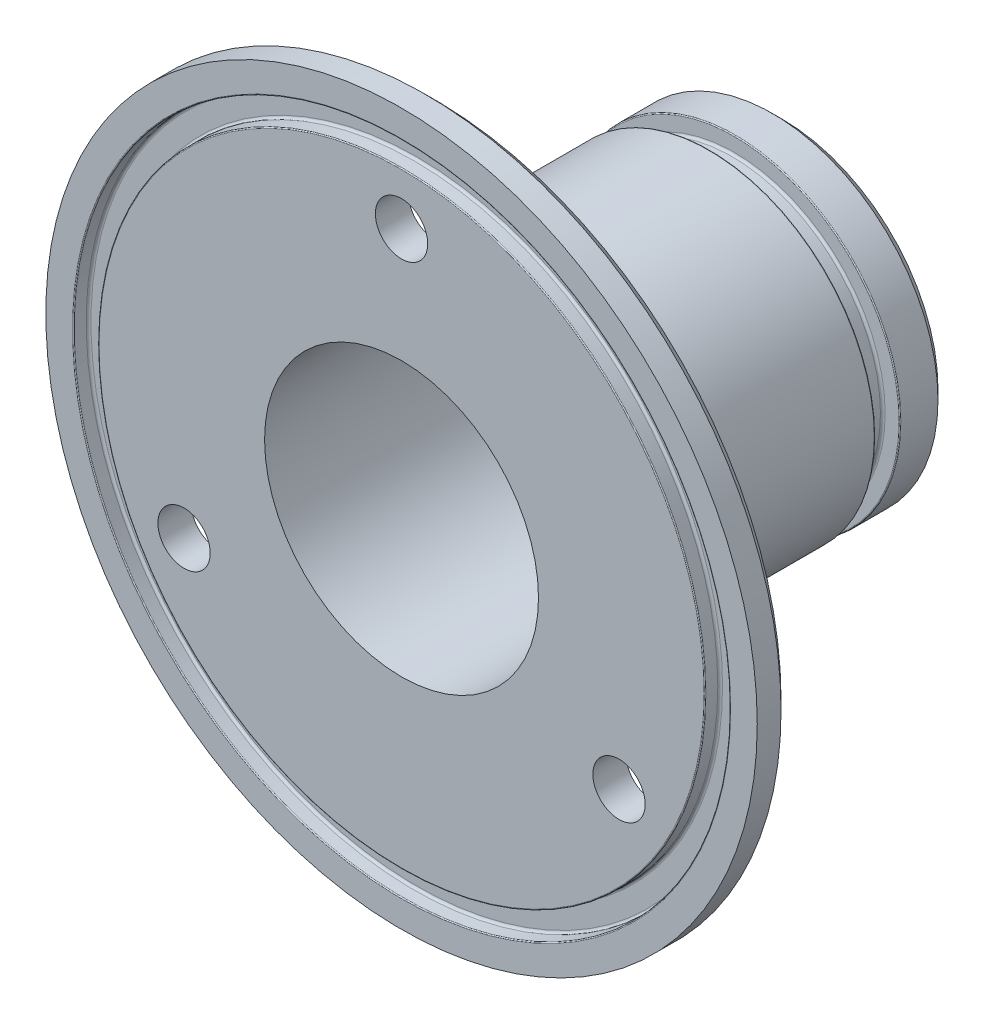
from build123d import *

# Parameters (mm, degrees)
SKETCH1_R           = 17.4
SKETCH1_R_2         = 14.4
BOSS_EXTRUDE1_DEPTH = 40
SKETCH2_R           = 37.4
SKETCH2_R_2         = 17.4
BOSS_EXTRUDE2_DEPTH = 3.5
SKETCH4_W           = 2.75
SKETCH4_H           = 3.5
CIRPATTERN1_COUNT   = 3
SKETCH5_W           = 1.8
SKETCH5_H           = 2.6
FILLET1_R           = 0.1
FILLET2_R           = 0.25
SKETCH6_R           = 34.5
SKETCH6_R_2         = 31.9
CUT_EXTRUDE1_DEPTH  = 1.6
FILLET3_R           = 0.25
FILLET4_R           = 0.1
CHAMFER1_SIZE       = 1
FILLET5_R           = 1
CHAMFER2_SIZE       = 1


with BuildPart() as part:
    # Sketch1 → Boss-Extrude1 (new body)
    with BuildSketch(Plane.XY):
        Circle(SKETCH1_R)
        Circle(SKETCH1_R_2, mode=Mode.SUBTRACT)
    extrude(amount=BOSS_EXTRUDE1_DEPTH)

    # Sketch5 → Cut-Revolve1 (revolve, cut)
    with BuildSketch(Plane(origin=(0, 0, 0), x_dir=(1, 0, 0), z_dir=(0, 1, 0))):
        with Locations((-16.5, -6.3)):
            Rectangle(SKETCH5_W, SKETCH5_H)
    revolve(axis=Axis((0, 0, 40), (0, 0, -1)), mode=Mode.SUBTRACT)

    # Fillet1
    fillet1_edges = [part.edges().sort_by_distance(p)[0] for p in [
        (-17.4, 0, 5),
        (-17.4, 0, 7.6),
    ]]
    fillet(fillet1_edges, radius=FILLET1_R)

    # Fillet2
    fillet2_edges = [part.edges().sort_by_distance(p)[0] for p in [
        (15.6, 0, 5),
        (15.6, 0, 7.6),
    ]]
    fillet(fillet2_edges, radius=FILLET2_R)


with BuildPart() as body_2:
    # Sketch2 → Boss-Extrude2 (new body)
    with BuildSketch(Plane.XY.offset(40)):
        Circle(SKETCH2_R)
        Circle(SKETCH2_R_2, mode=Mode.SUBTRACT)
    extrude(amount=-BOSS_EXTRUDE2_DEPTH)

    # Sketch4 → M5 Clearance Hole1 (revolve, cut)
    with BuildSketch(Plane(origin=(0, 26.4, 36.5), x_dir=(0, 1, 0), z_dir=(1, 0, 0))):
        with Locations((1.375, 1.75)):
            Rectangle(SKETCH4_W, SKETCH4_H)
    m5_clearance_hole1 = revolve(axis=Axis((0, 26.4, 30.15), (0, 0, 1)), mode=Mode.SUBTRACT)

    # CirPattern1: M5 Clearance Hole1 ×3 about axis
    cirpattern1_axis = Axis((0, 0, 0), (0, 0, 1))
    for i in range(1, CIRPATTERN1_COUNT):
        add(m5_clearance_hole1.rotate(cirpattern1_axis, i * 360 / CIRPATTERN1_COUNT), mode=Mode.SUBTRACT)


with BuildPart() as part_1:
    add(part.part)

    # Combine1: union body 2
    add(body_2.part)

    # Sketch6 → Cut-Extrude1 (cut)
    with BuildSketch(Plane.XY.offset(40)):
        Circle(SKETCH6_R)
        Circle(SKETCH6_R_2, mode=Mode.SUBTRACT)
    extrude(amount=-CUT_EXTRUDE1_DEPTH, mode=Mode.SUBTRACT)

    # Fillet3
    fillet3_edges = [part_1.edges().sort_by_distance(p)[0] for p in [
        (-34.5, 0, 38.4),
        (-31.9, 0, 38.4),
    ]]
    fillet(fillet3_edges, radius=FILLET3_R)

    # Fillet4
    fillet4_edges = [part_1.edges().sort_by_distance(p)[0] for p in [
        (-34.5, 0, 40),
        (-31.9, 0, 40),
    ]]
    fillet(fillet4_edges, radius=FILLET4_R)

    # Chamfer1
    chamfer1_edges = [part_1.edges().sort_by_distance(p)[0] for p in [
        (-37.4, 0, 36.5),
    ]]
    chamfer(chamfer1_edges, length=CHAMFER1_SIZE)

    # Fillet5
    fillet5_edges = [part_1.edges().sort_by_distance(p)[0] for p in [
        (-17.4, 0, 36.5),
    ]]
    fillet(fillet5_edges, radius=FILLET5_R)

    # Chamfer2
    chamfer2_edges = [part_1.edges().sort_by_distance(p)[0] for p in [
        (-17.4, 0, 0),
    ]]
    chamfer(chamfer2_edges, length=CHAMFER2_SIZE)


solid = part_1.part
